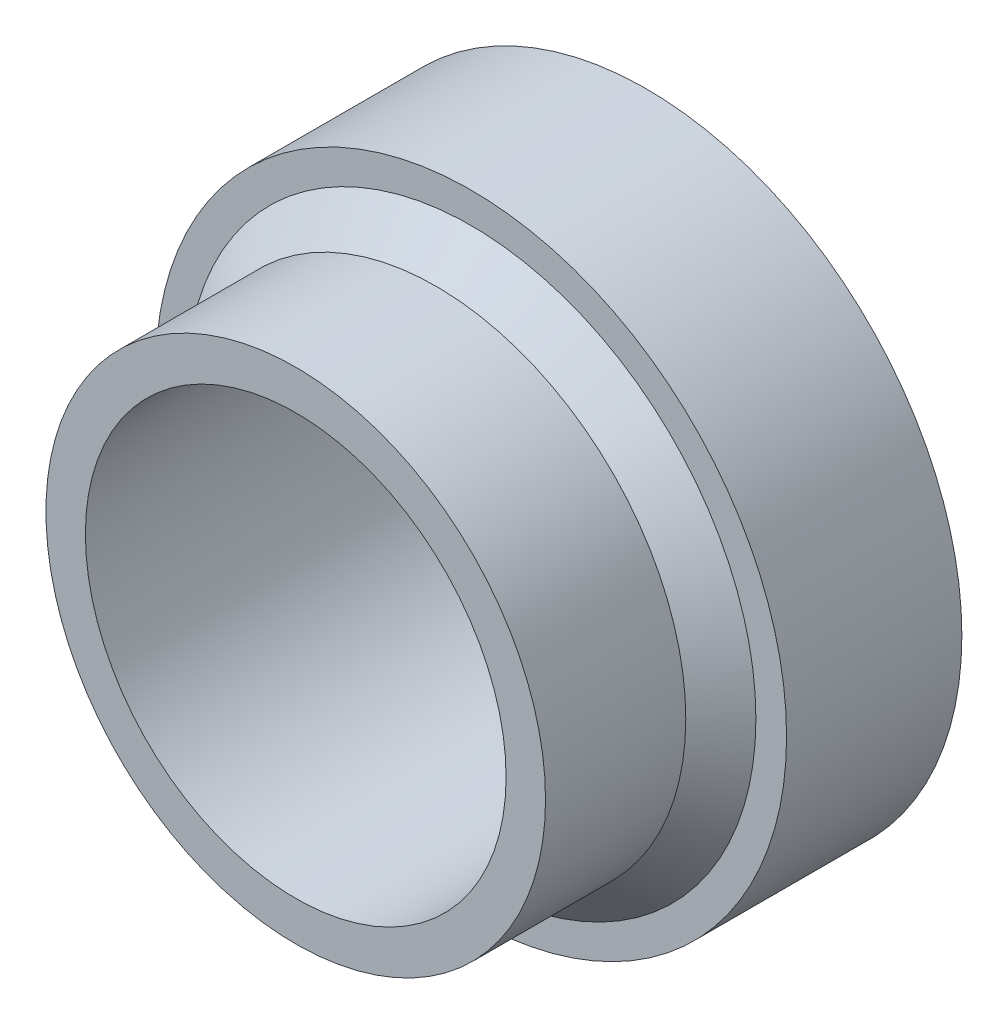
from build123d import *

# Parameters (mm, degrees)
SKETCH1_R           = 18
SKETCH1_R_2         = 12
BOSS_EXTRUDE1_DEPTH = 10
SKETCH3_R           = 14.2
CUT_EXTRUDE1_DEPTH  = 1.75
SKETCH5_R           = 14.25
SKETCH5_R_2         = 12
BOSS_EXTRUDE2_DEPTH = 10
CHAMFER1_SIZE       = 2


with BuildPart() as part:
    # Sketch1 → Boss-Extrude1 (new body)
    with BuildSketch(Plane.XY):
        Circle(SKETCH1_R)
        Circle(SKETCH1_R_2, mode=Mode.SUBTRACT)
    extrude(amount=BOSS_EXTRUDE1_DEPTH)

    # Sketch3 → Cut-Extrude1 (cut)
    with BuildSketch(Plane.XY):
        Circle(SKETCH3_R)
    extrude(amount=CUT_EXTRUDE1_DEPTH, mode=Mode.SUBTRACT)

    # Sketch5 → Boss-Extrude2 (add)
    with BuildSketch(Plane.XY.offset(10)):
        Circle(SKETCH5_R)
        Circle(SKETCH5_R_2, mode=Mode.SUBTRACT)
    extrude(amount=BOSS_EXTRUDE2_DEPTH)

    # Chamfer1
    chamfer1_edges = [part.edges().sort_by_distance(p)[0] for p in [
        (-14.25, 0, 10),
    ]]
    chamfer(chamfer1_edges, length=CHAMFER1_SIZE)


solid = part.part
